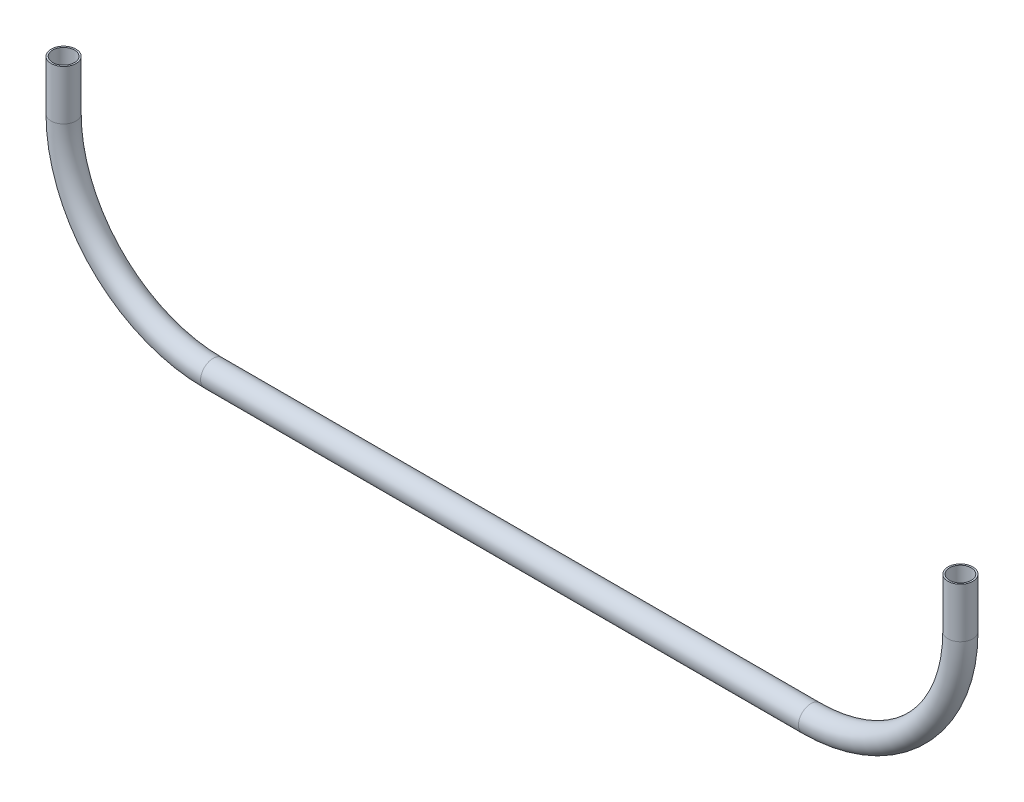
from build123d import *

# Parameters (mm, degrees)
SKETCH2_R   = 6.35
SKETCH2_R_2 = 5.55625


with BuildPart() as part:
    # Sweep1: sweep along a path in Sketch1
    with BuildLine(Plane.XY) as sweep1_path:
        Line((-228.6, 101.6), (-228.6, 76.2))
        ThreePointArc((-228.6, 76.2), (-206.281536726, 22.318463274), (-152.4, 0))
        Line((-152.4, 0), (152.4, 0))
        ThreePointArc((152.4, 0), (206.281536726, 22.318463274), (228.6, 76.2))
        Line((228.6, 76.2), (228.6, 101.6))
    # Sketch2 → Sweep1 (sweep)
    with BuildSketch(Plane(origin=(-228.6, 101.6, 0), x_dir=(1, 0, 0), z_dir=(0, 1, 0))):
        Circle(SKETCH2_R)
        Circle(SKETCH2_R_2, mode=Mode.SUBTRACT)
    sweep(path=sweep1_path.line)


solid = part.part
